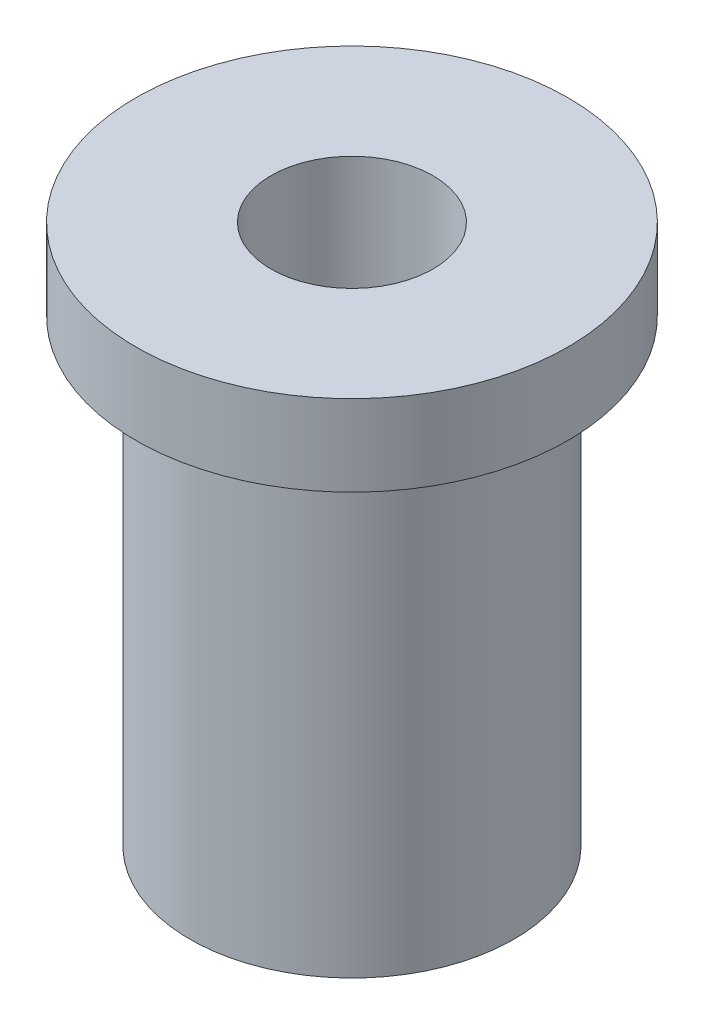
from build123d import *


with BuildPart() as part:
    # Esquisse1 → Révolution1 (revolve)
    with BuildSketch(Plane.XY, mode=Mode.PRIVATE) as r_volution1_sk:
        Polygon((3, 0), (3, 20), (8, 20), (8, 17), (6, 17), (6, 0), align=None)
    revolve(r_volution1_sk.sketch.rotate(Axis((0, 0, 0), (0, 1, 0)), 90), axis=Axis((0, 0, 0), (0, 1, 0)))  # turned: the seam where the file's is


solid = part.part
